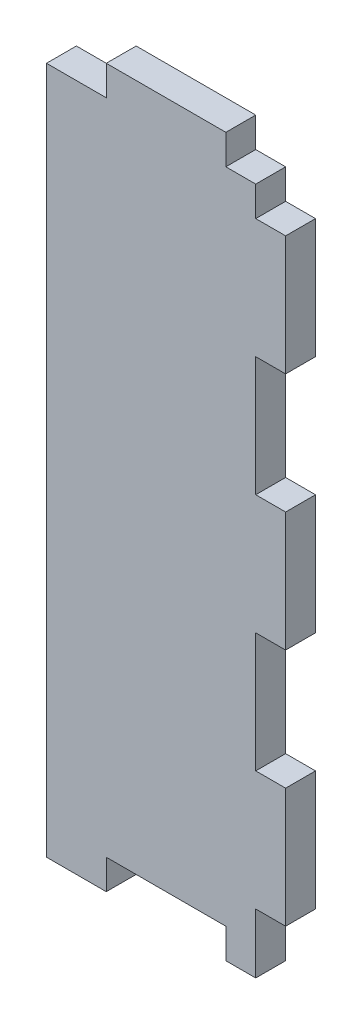
from build123d import *

# Parameters (mm, degrees)
SKETCH1_W          = 25.4
SKETCH1_H          = 76.2
EXTRUDE1_DEPTH     = 3.175
SKETCH3_W          = 3.175
SKETCH3_H          = 6.35
CUT_EXTRUDE1_DEPTH = 3.175
LPATTERN1_COUNT    = 3
LPATTERN1_PITCH    = 69.85
SKETCH4_W          = 3.175
SKETCH4_H          = 12.7
CUT_EXTRUDE2_DEPTH = 3.175
LPATTERN2_COUNT    = 2
LPATTERN2_PITCH    = 25.4
SKETCH5_W          = 12.7
SKETCH5_H          = 3.175
CUT_EXTRUDE3_DEPTH = 3.175
SKETCH6_W          = 6.35
SKETCH6_H          = 3.175
CUT_EXTRUDE4_DEPTH = 3.175
LPATTERN3_COUNT    = 2
LPATTERN3_PITCH    = 19.05


with BuildPart() as part:
    # Sketch1 → Extrude1 (new body)
    with BuildSketch(Plane.XY):
        with Locations((12.7, 38.1)):
            Rectangle(SKETCH1_W, SKETCH1_H)
    extrude(amount=EXTRUDE1_DEPTH)

    # Sketch3 → Cut-Extrude1 (cut)
    with BuildSketch(Plane.XY.offset(3.175)):
        with Locations((23.8125, 73.025)):
            Rectangle(SKETCH3_W, SKETCH3_H)
    cut_extrude1 = extrude(amount=-CUT_EXTRUDE1_DEPTH, mode=Mode.SUBTRACT)

    # LPattern1: Cut-Extrude1 ×3
    with Locations(*[(0, -i * LPATTERN1_PITCH, 0) for i in range(1, LPATTERN1_COUNT)]):
        add(cut_extrude1, mode=Mode.SUBTRACT)

    # Sketch4 → Cut-Extrude2 (cut)
    with BuildSketch(Plane.XY.offset(3.175)):
        with Locations((23.8125, 50.8)):
            Rectangle(SKETCH4_W, SKETCH4_H)
    cut_extrude2 = extrude(amount=-CUT_EXTRUDE2_DEPTH, mode=Mode.SUBTRACT)

    # LPattern2: Cut-Extrude2 ×2
    with Locations(*[(0, -i * LPATTERN2_PITCH, 0) for i in range(1, LPATTERN2_COUNT)]):
        add(cut_extrude2, mode=Mode.SUBTRACT)

    # Sketch5 → Cut-Extrude3 (cut)
    with BuildSketch(Plane.XY.offset(3.175)):
        with Locations((12.7, 1.5875)):
            Rectangle(SKETCH5_W, SKETCH5_H)
    extrude(amount=-CUT_EXTRUDE3_DEPTH, mode=Mode.SUBTRACT)

    # Sketch6 → Cut-Extrude4 (cut)
    with BuildSketch(Plane.XY.offset(3.175)):
        with Locations((3.175, 74.6125)):
            Rectangle(SKETCH6_W, SKETCH6_H)
    cut_extrude4 = extrude(amount=-CUT_EXTRUDE4_DEPTH, mode=Mode.SUBTRACT)

    # LPattern3: Cut-Extrude4 ×2
    with Locations(*[(i * LPATTERN3_PITCH, 0, 0) for i in range(1, LPATTERN3_COUNT)]):
        add(cut_extrude4, mode=Mode.SUBTRACT)


solid = part.part
